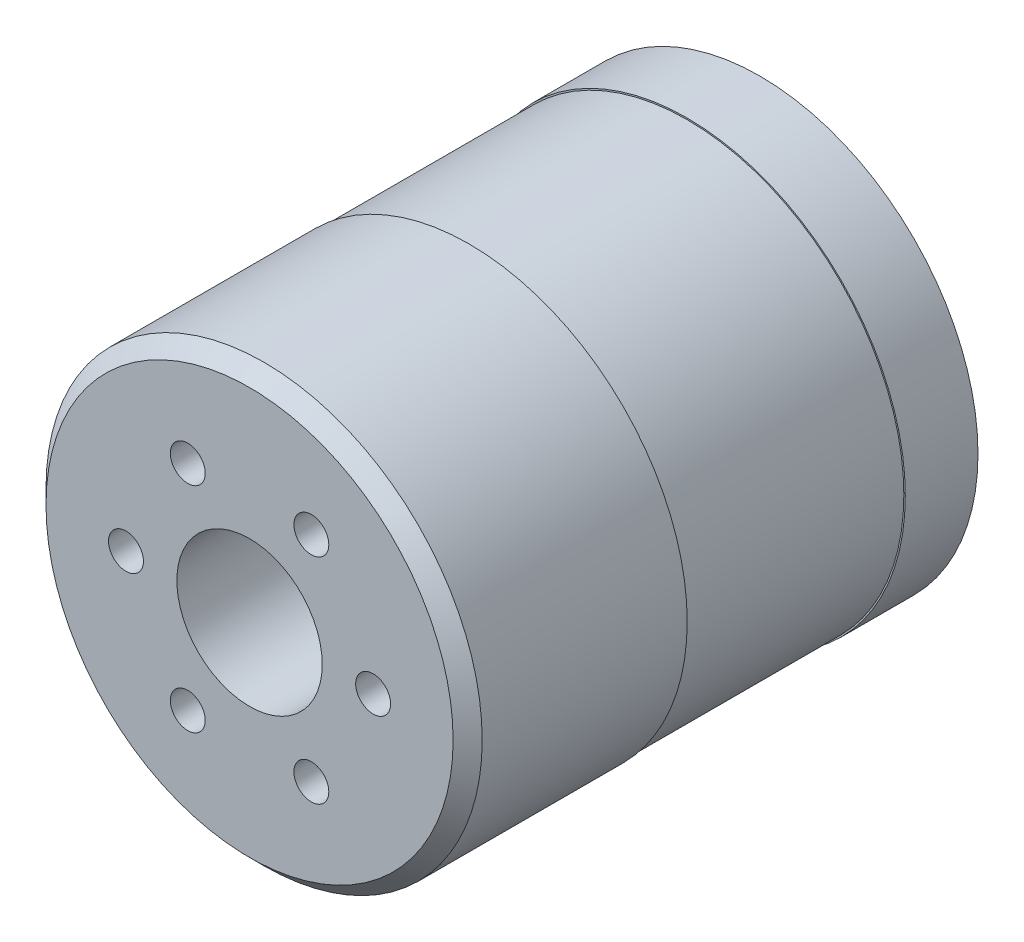
from build123d import *

# Parameters (mm, degrees)
ESQUISSE1_R             = 15
EXTRUSION1_DEPTH        = 35.1
ESQUISSE2_R             = 9
EXTRUSION2_DEPTH        = 4
ESQUISSE3_R             = 5
EXTRUSION3_DEPTH        = 0.5
CHANFREIN1_SIZE         = 1
ENL_V_MAT_EXTRU_1_REACH = 6.5
ESQUISSE7_R             = 4
ESQUISSE8_R             = 15
ESQUISSE8_R_2           = 14.9
ENL_V_MAT_EXTRU_2_DEPTH = 20
ESQUISSE9_R             = 15
EXTRUSION4_DEPTH        = 5
TROU_TARAUD_M31_D       = 2.5
TROU_TARAUD_M31_DEPTH   = 4.5
TROU_TARAUD_M31_TIP     = 0.751075774
ESQUISSE10_R            = 5
ENL_V_MAT_EXTRU_3_DEPTH = 15
D_GAGEMENT_M21_D        = 2.4
D_GAGEMENT_M21_DEPTH    = 3
D_GAGEMENT_M21_TIP      = 0.721032743


with BuildPart() as part:
    # Esquisse1 → Extrusion1 (new body)
    with BuildSketch(Plane.XY):
        Circle(ESQUISSE1_R)
    extrude(amount=EXTRUSION1_DEPTH)

    # Esquisse2 → Extrusion2 (add)
    with BuildSketch(Plane(origin=(0, 0, 0), x_dir=(-1, 0, 0), z_dir=(0, 0, -1))):
        Circle(ESQUISSE2_R)
    extrude(amount=EXTRUSION2_DEPTH)

    # Esquisse3 → Extrusion3 (add)
    with BuildSketch(Plane(origin=(0, 0, -4), x_dir=(-1, 0, 0), z_dir=(0, 0, -1))):
        Circle(ESQUISSE3_R)
    extrude(amount=EXTRUSION3_DEPTH)

    # Chanfrein1
    chanfrein1_edges = [part.edges().sort_by_distance(p)[0] for p in [
        (-15, 0, 35.1),
    ]]
    chamfer(chanfrein1_edges, length=CHANFREIN1_SIZE)

    # Esquisse7 → Enlèv. mat.-Extru.1 (cut, up to next)
    with BuildSketch(Plane(origin=(0, 0, 0), x_dir=(-1, 0, 0), z_dir=(0, 0, -1)), mode=Mode.PRIVATE) as enl_v_mat_extru_1_sk1:
        Circle(ESQUISSE7_R)
    enl_v_mat_extru_1_tool1 = extrude(enl_v_mat_extru_1_sk1.sketch, amount=ENL_V_MAT_EXTRU_1_REACH, mode=Mode.PRIVATE) & part.part
    add(enl_v_mat_extru_1_tool1.solids().sort_by_distance((0, 0, 0))[0], mode=Mode.SUBTRACT)

    # Esquisse8 → Enlèv. mat.-Extru.2 (cut)
    with BuildSketch(Plane(origin=(0, 0, 0), x_dir=(-1, 0, 0), z_dir=(0, 0, -1))):
        Circle(ESQUISSE8_R)
        Circle(ESQUISSE8_R_2, mode=Mode.SUBTRACT)
    extrude(amount=-ENL_V_MAT_EXTRU_2_DEPTH, mode=Mode.SUBTRACT)

    # Esquisse9 → Extrusion4 (add)
    with BuildSketch(Plane(origin=(0, 0, 0), x_dir=(-1, 0, 0), z_dir=(0, 0, -1))):
        Circle(ESQUISSE9_R)
    extrude(amount=-EXTRUSION4_DEPTH)

    # Trou taraudé M31
    with Locations(Plane(origin=(0, 0, 0), x_dir=(-1, 0, 0), z_dir=(0, 0, -1))):
        with Locations((13, 0), (0, 13), (-13, 0), (0, -13)):
            Hole(TROU_TARAUD_M31_D / 2, depth=TROU_TARAUD_M31_DEPTH)
            with Locations((0, 0, -(TROU_TARAUD_M31_DEPTH + TROU_TARAUD_M31_TIP / 2))):  # 118° drill point
                Cone(0, TROU_TARAUD_M31_D / 2, TROU_TARAUD_M31_TIP, mode=Mode.SUBTRACT)

    # Esquisse10 → Enlèv. mat.-Extru.3 (cut)
    with BuildSketch(Plane.XY.offset(35.1)):
        Circle(ESQUISSE10_R)
    extrude(amount=-ENL_V_MAT_EXTRU_3_DEPTH, mode=Mode.SUBTRACT)

    # Dégagement M21
    with Locations(Plane.XY.offset(35.1)):
        with Locations((4.25, -7.361215932), (-4.25, -7.361215932), (-8.5, 0), (-4.25, 7.361215932), (4.25, 7.361215932), (8.5, 0)):
            Hole(D_GAGEMENT_M21_D / 2, depth=D_GAGEMENT_M21_DEPTH)
            with Locations((0, 0, -(D_GAGEMENT_M21_DEPTH + D_GAGEMENT_M21_TIP / 2))):  # 118° drill point
                Cone(0, D_GAGEMENT_M21_D / 2, D_GAGEMENT_M21_TIP, mode=Mode.SUBTRACT)


solid = part.part
